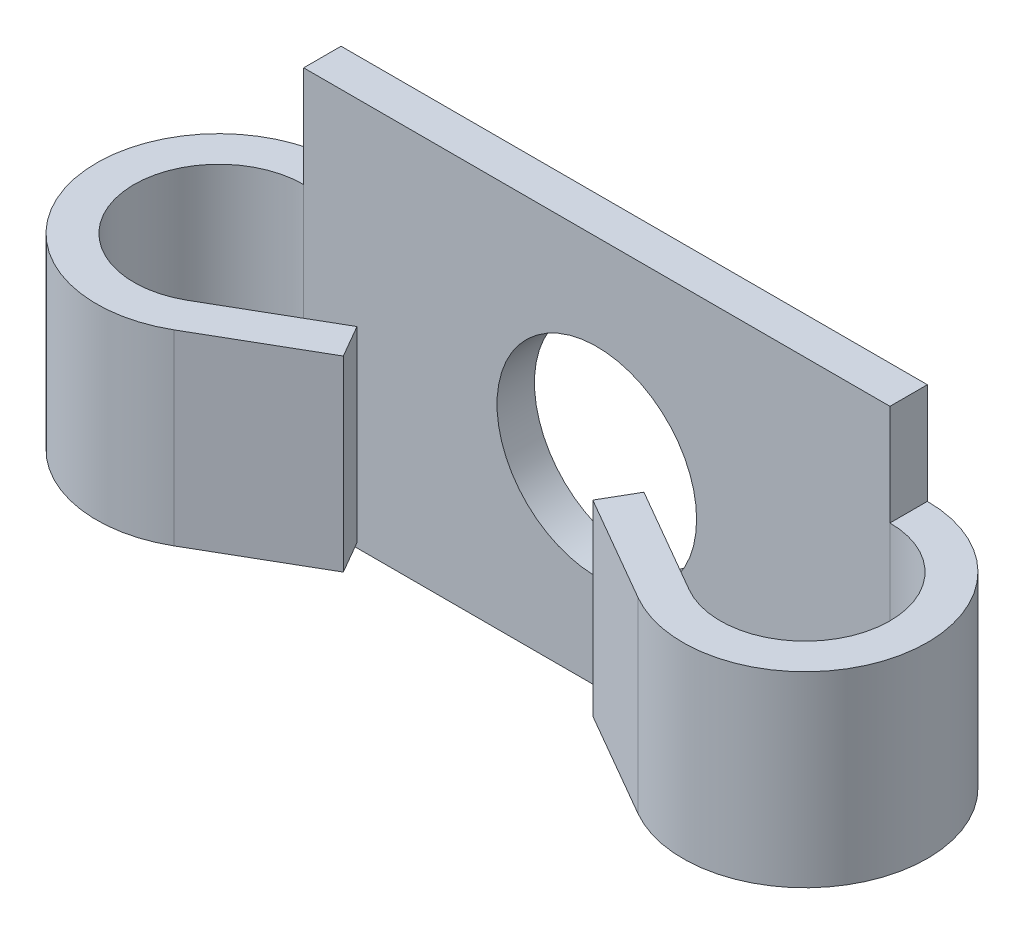
from build123d import *

# Parameters (mm, degrees)
SKETCH_1_W      = 23.5
SKETCH_1_H      = 15.6
SKETCH_1_R      = 4
EXTRUDE_1_DEPTH = 1.5
EXTRUDE_2_DEPTH = 3.75


with BuildPart() as part:
    # Эскиз1 → Бобышка-Вытянуть1 (new body)
    with BuildSketch(Plane.XY):
        Rectangle(SKETCH_1_W, SKETCH_1_H)
        Circle(SKETCH_1_R, mode=Mode.SUBTRACT)
    extrude(amount=EXTRUDE_1_DEPTH)

    # Эскиз3 → Бобышка-Вытянуть2 (add, symmetric)
    with BuildSketch(Plane(origin=(0, 0, 0), x_dir=(1, 0, 0), z_dir=(0, 1, 0))):
        with BuildLine():
            Line((-10.05, -7.844486373), (-5.75, -5.361880215))
            Line((-5.75, -5.361880215), (-5, -6.660918321))
            Line((-5, -6.660918321), (-9.3, -9.143524479))
            ThreePointArc((-9.3, -9.143524479), (-16.483036549, -6.168213321), (-11.75, 0))
            Line((-11.75, 0), (-11.75, -1.5))
            ThreePointArc((-11.75, -1.5), (-15.034147809, -5.779984753), (-10.05, -7.844486373))
        make_face()
    extrude_2 = extrude(amount=EXTRUDE_2_DEPTH, both=True)

    # Зеркальное отражение1: Бобышка-Вытянуть2 across plane
    add(extrude_2.mirror(Plane(origin=(0, 0, 0), x_dir=(0, 0, 1), z_dir=(1, 0, 0))))


solid = part.part
